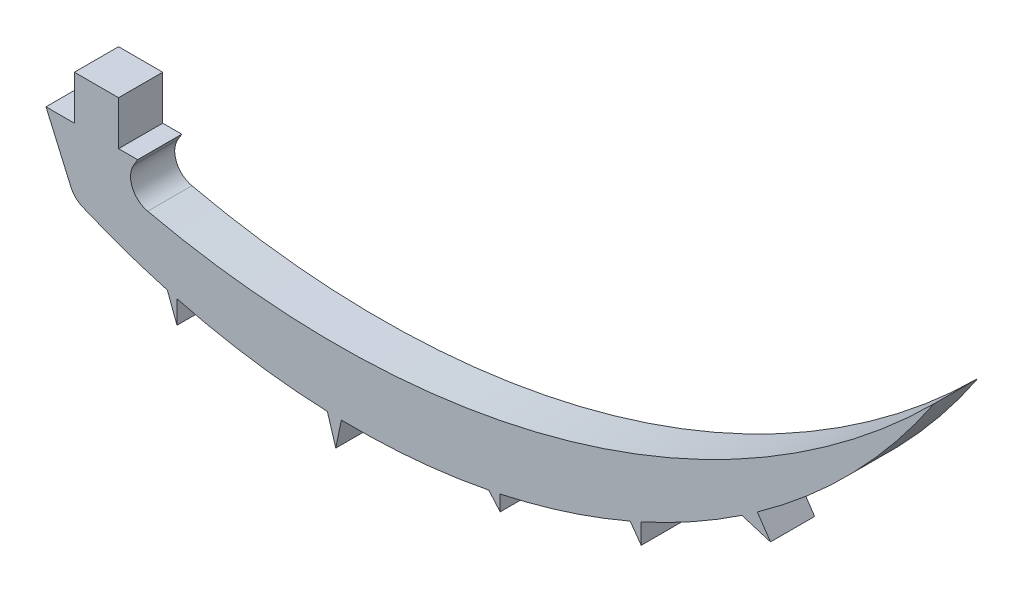
from build123d import *

# Parameters (mm, degrees)
BOSS_EXTRUDE1_DEPTH = 1.524
FILLET1_R           = 0.762
FILLET2_R           = 0.762


with BuildPart() as part:
    # Sketch1 → Boss-Extrude1 (new body)
    with BuildSketch(Plane.XY):
        with BuildLine():
            Line((6.433464338, 1.524), (4.909464338, 1.524))
            Line((4.909464338, 1.524), (4.909464338, 0))
            Line((4.909464338, 0), (3.929779176, 0))
            Line((3.929779176, 0), (4.909464338, -2.240840662))
            ThreePointArc((4.909464338, -2.240840662), (6.492968468, -2.870194257), (8.117099911, -3.385721496))
            Line((8.117099911, -3.385721496), (8.449939435, -4.268236242))
            Line((8.449939435, -4.268236242), (8.449939435, -3.47594469))
            ThreePointArc((8.449939435, -3.47594469), (11.023079362, -4.00513675), (13.638615108, -4.250220566))
            Line((13.638615108, -4.250220566), (13.928033002, -5.200165059))
            Line((13.928033002, -5.200165059), (14.121765671, -4.264076161))
            ThreePointArc((14.121765671, -4.264076161), (16.676471214, -4.175606926), (19.207315416, -3.816197909))
            Line((19.207315416, -3.816197909), (19.602084403, -4.268236242))
            Line((19.602084403, -4.268236242), (19.602084403, -3.735071341))
            ThreePointArc((19.602084403, -3.735071341), (21.879297331, -3.128958074), (24.086174716, -2.302662594))
            Line((24.086174716, -2.302662594), (24.468474935, -2.834558551))
            Line((24.468474935, -2.834558551), (24.468474935, -2.133758289))
            ThreePointArc((24.468474935, -2.133758289), (26.244740547, -1.240138243), (27.941024881, -0.202691489))
            Line((27.941024881, -0.202691489), (28.929332922, -0.502746421))
            Line((28.929332922, -0.502746421), (28.474650124, 0.165358914))
            ThreePointArc((28.474650124, 0.165358914), (31.807513974, 3.022993189), (34.564707679, 6.439414997))
            ThreePointArc((34.564707679, 6.439414997), (21.508001683, -1.0948152), (6.433464338, -1.117618174))
            Line((6.433464338, -1.117618174), (7.091019013, 0))
            Line((7.091019013, 0), (6.433464338, 0))
            Line((6.433464338, 0), (6.433464338, 1.524))
        make_face()
    extrude(amount=BOSS_EXTRUDE1_DEPTH)

    # Fillet1
    fillet1_edges = [part.edges().sort_by_distance(p)[0] for p in [
        (6.433464338, -1.117618174, 0.762),
    ]]
    fillet(fillet1_edges, radius=FILLET1_R)

    # Fillet2
    fillet2_edges = [part.edges().sort_by_distance(p)[0] for p in [
        (4.909464338, -2.240840662, 0.762),
    ]]
    fillet(fillet2_edges, radius=FILLET2_R)


solid = part.part
